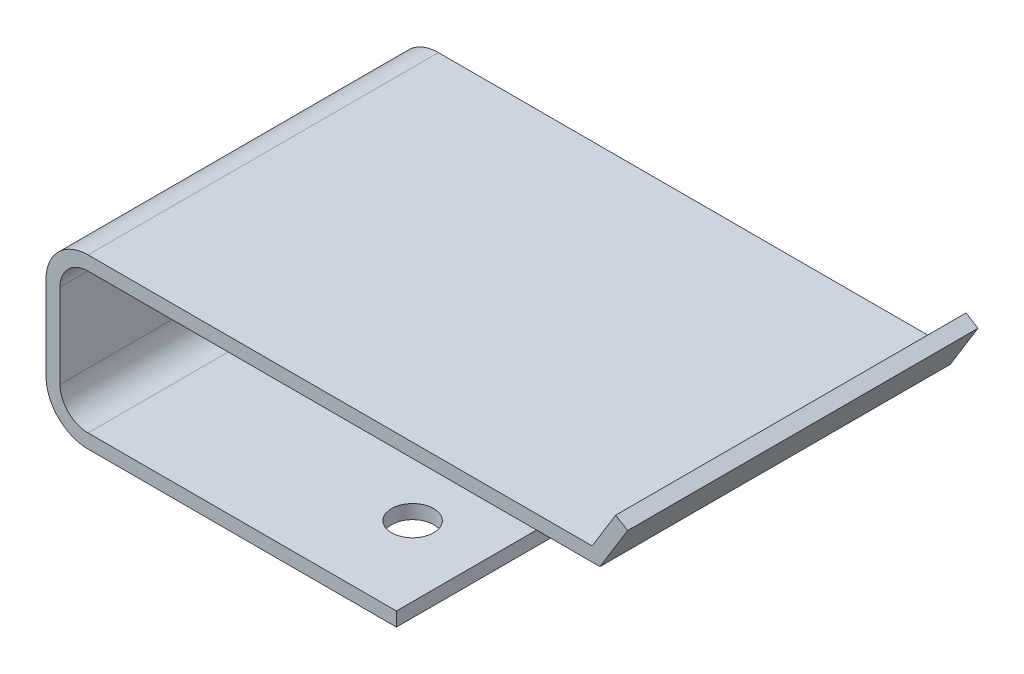
from build123d import *

# Parameters (mm, degrees)
EXTRUS_O_FINA1_DEPTH  = 25
ESBO_O2_R             = 1.5
CORTE_EXTRUS_O1_DEPTH = 5


with BuildPart() as part:
    # Esboço1 → Extrusão-Fina1 (new body)
    with BuildSketch(Plane.XY):
        with BuildLine():
            Line((0, 0), (-22, 0))
            ThreePointArc((-22, 0), (-24.121320344, 0.878679656), (-25, 3))
            Line((-25, 3), (-25, 9))
            ThreePointArc((-25, 9), (-24.121320344, 11.121320344), (-22, 12))
            Line((-22, 12), (-10, 12))
            Line((-10, 12), (13.964550925, 12))
            Line((13.964550925, 12), (15.645056047, 14.73834825))
            Line((15.645056047, 14.73834825), (16.497357261, 14.215296971))
            Line((16.497357261, 14.215296971), (14.524152053, 11))
            Line((14.524152053, 11), (-10, 11))
            Line((-10, 11), (-22, 11))
            ThreePointArc((-22, 11), (-23.414213562, 10.414213562), (-24, 9))
            Line((-24, 9), (-24, 3))
            ThreePointArc((-24, 3), (-23.414213562, 1.585786438), (-22, 1))
            Line((-22, 1), (0, 1))
            Line((0, 1), (0, 0))
        make_face()
    extrude(amount=EXTRUS_O_FINA1_DEPTH)

    # Esboço2 → Corte-extrusão1 (cut)
    with BuildSketch(Plane.XZ):
        with Locations((-5, 18.842376972)):
            Circle(ESBO_O2_R)
        with Locations((-5, 3.904607357)):
            Circle(ESBO_O2_R)
    extrude(amount=-CORTE_EXTRUS_O1_DEPTH, mode=Mode.SUBTRACT)


solid = part.part
